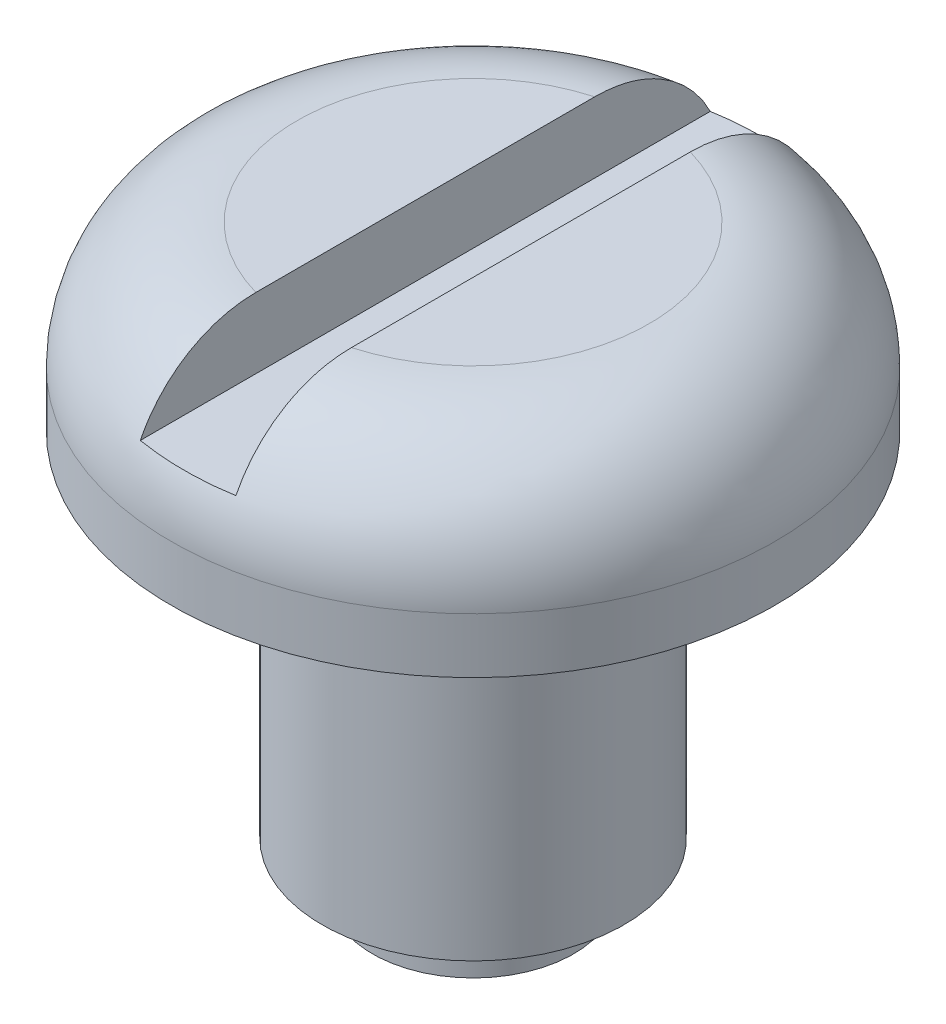
from build123d import *

# Parameters (mm, degrees)
SKETCH2_W               = 1.9
SKETCH2_H               = 1.4
CUT_EXTRUDE1_DEPTH      = 7
CUT_EXTRUDE1_DEPTH_BACK = 7


with BuildPart() as part:
    # Sketch1 → Revolve1 (revolve)
    with BuildSketch(Plane.XY):
        with BuildLine():
            Line((0, 0), (2, 0))
            Line((2, 0), (2, 1))
            Line((2, 1), (3, 1))
            Line((3, 1), (3, 8))
            Line((3, 8), (6, 8))
            Line((6, 8), (6, 9.1))
            ThreePointArc((6, 9.1), (5.267766953, 10.867766953), (3.5, 11.6))
            Line((3.5, 11.6), (0, 11.6))
            Line((0, 11.6), (0, 0))
        make_face()
    revolve(axis=Axis((0, 0, 0), (0, 1, 0)))

    # Sketch2 → Cut-Extrude1 (cut, two sides)
    with BuildSketch(Plane.XY) as cut_extrude1_sk:
        with Locations((0, 10.9)):
            Rectangle(SKETCH2_W, SKETCH2_H)
    extrude(amount=CUT_EXTRUDE1_DEPTH, mode=Mode.SUBTRACT)
    extrude(cut_extrude1_sk.sketch, amount=-CUT_EXTRUDE1_DEPTH_BACK, mode=Mode.SUBTRACT)


solid = part.part
